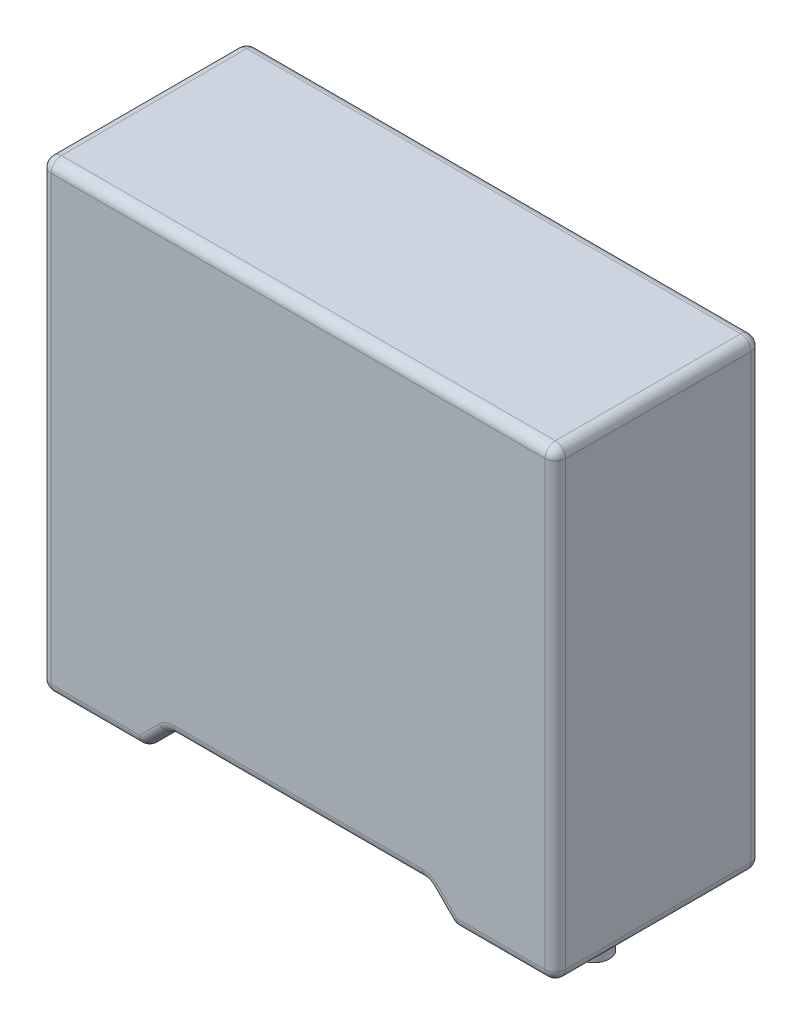
from build123d import *

# Parameters (mm, degrees)
SKETCH1_W           = 10
SKETCH1_H           = 4
BOSS_EXTRUDE1_DEPTH = 9
CUT_EXTRUDE1_DEPTH  = 5
SKETCH3_R           = 0.3
BOSS_EXTRUDE2_DEPTH = 1
FILLET1_R           = 0.2


with BuildPart() as part:
    # Sketch1 → Boss-Extrude1 (new body)
    with BuildSketch(Plane(origin=(0, 0, 0), x_dir=(1, 0, 0), z_dir=(0, 1, 0))):
        Rectangle(SKETCH1_W, SKETCH1_H)
    extrude(amount=BOSS_EXTRUDE1_DEPTH)

    # Sketch2 → Cut-Extrude1 (cut, through all)
    with BuildSketch(Plane.XY.offset(2)):
        Polygon((-3, 0), (-2.5, 0.5), (2.5, 0.5), (3, 0), (3, -1.5), (-3, -1.5), align=None)
    extrude(amount=-CUT_EXTRUDE1_DEPTH, mode=Mode.SUBTRACT)

    # Sketch3 → Boss-Extrude2 (add)
    with BuildSketch(Plane.XZ):
        with Locations((3.75, 0)):
            Circle(SKETCH3_R)
        with Locations((-3.75, 0)):
            Circle(SKETCH3_R)
    extrude(amount=BOSS_EXTRUDE2_DEPTH)

    # Fillet1
    fillet1_edges = [part.edges().sort_by_distance(p)[0] for p in [
        (5, 9, 0),
        (0, 9, -2),
        (-4, 0, -2),
        (4, 0, 2),
        (2.75, 0.25, 2),
        (0, 0.5, 2),
        (-2.75, 0.25, 2),
        (-2.75, 0.25, -2),
        (-3, 0, 0),
        (0, 0.5, -2),
        (-2.5, 0.5, 0),
        (2.75, 0.25, -2),
        (2.5, 0.5, 0),
        (3, 0, 0),
        (-5, 9, 0),
        (4, 0, -2),
        (5, 0, 0),
        (-4, 0, 2),
        (-5, 0, 0),
        (0, 9, 2),
        (-5, 4.5, -2),
        (5, 4.5, -2),
        (5, 4.5, 2),
        (-5, 4.5, 2),
    ]]
    fillet(fillet1_edges, radius=FILLET1_R)


solid = part.part
